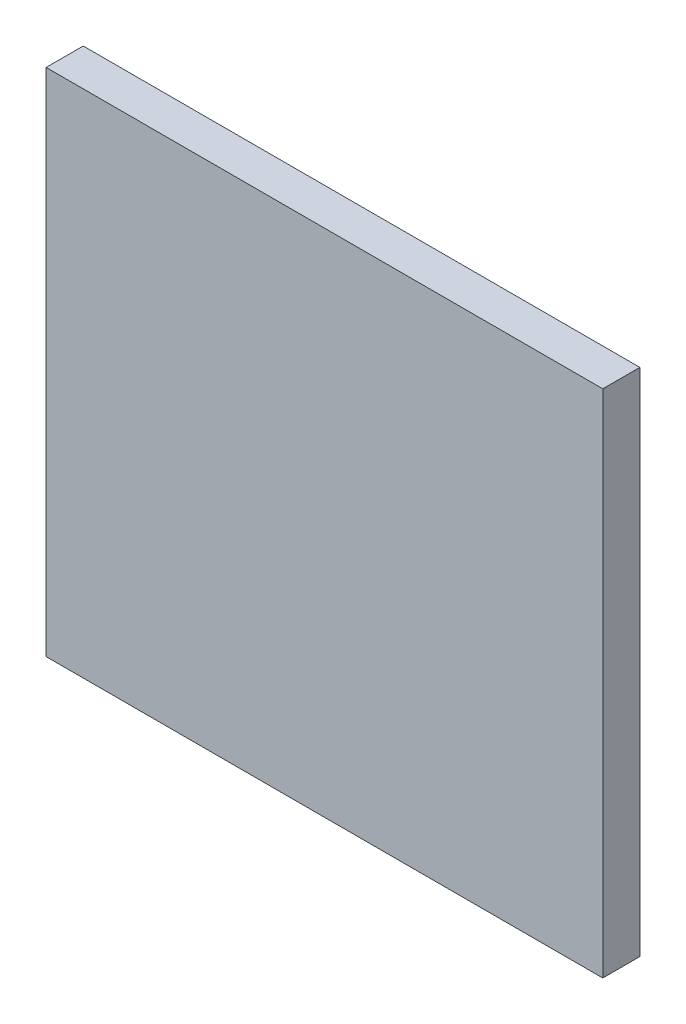
from build123d import *

# Parameters (mm, degrees)
SCHIZZO2_W                   = 12
SCHIZZO2_H                   = 11
ESTRUSIONE_ESTRUSIONE1_DEPTH = 0.8


with BuildPart() as part:
    # Schizzo2 → Estrusione-Estrusione1 (new body)
    with BuildSketch(Plane.XY):
        Rectangle(SCHIZZO2_W, SCHIZZO2_H)
    extrude(amount=ESTRUSIONE_ESTRUSIONE1_DEPTH)


solid = part.part
